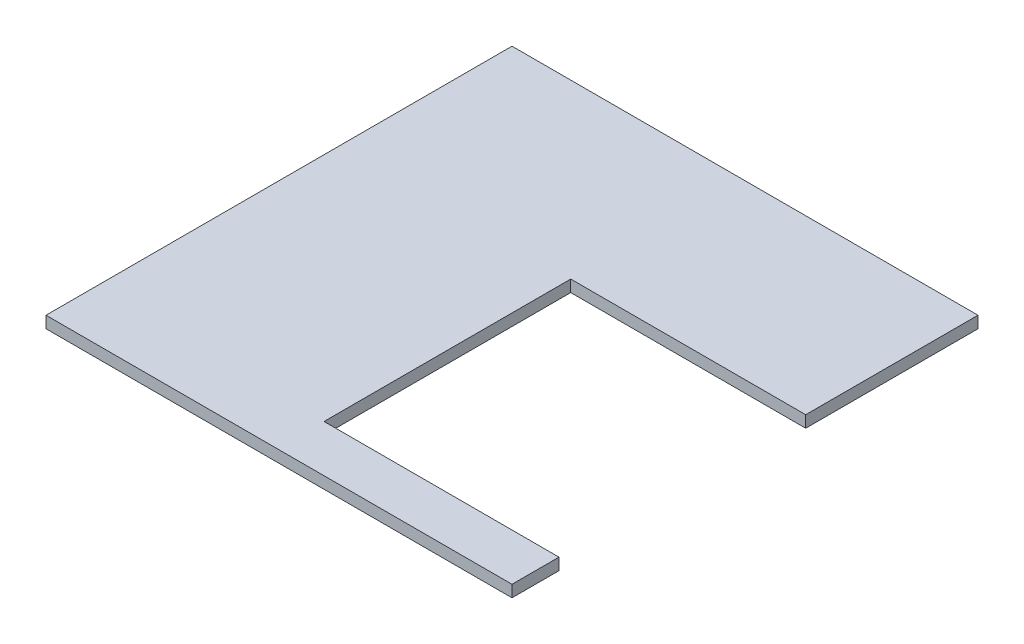
from build123d import *

# Parameters (mm, degrees)
BOSS_EXTRU_1_DEPTH = 3


with BuildPart() as part:
    # Esquisse1 → Boss.-Extru.1 (new body)
    with BuildSketch(Plane(origin=(0, 0, 0), x_dir=(1, 0, 0), z_dir=(0, 1, 0))):
        Polygon((0, 119), (0, 0), (119, 0), (119, 12), (59, 12), (59, 75), (119, 75), (119, 119), align=None)
    extrude(amount=BOSS_EXTRU_1_DEPTH)


solid = part.part
